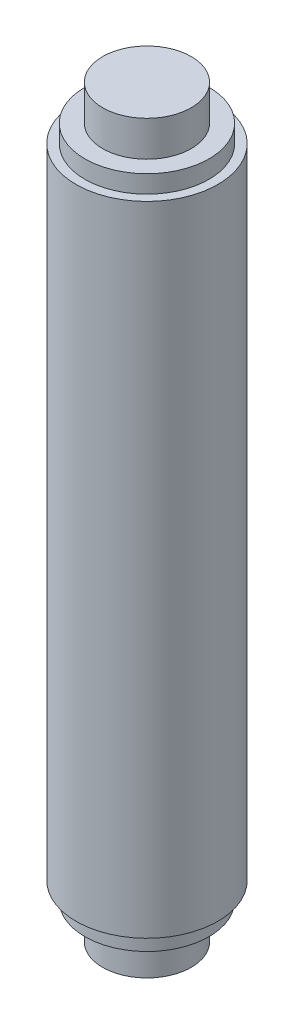
from build123d import *


with BuildPart() as part:
    # Sketch1 → Revolve1 (revolve)
    with BuildSketch(Plane.XY):
        Polygon((0, 21), (0, 0), (4, 0), (4, 18), (3.5, 18), (3.5, 19), (2.5, 19), (2.5, 21), align=None)
    revolve1 = revolve(axis=Axis((0, 21, 0), (0, -1, 0)))

    # Mirror1: Revolve1 across plane
    add(revolve1.mirror(Plane.ZX))


solid = part.part
